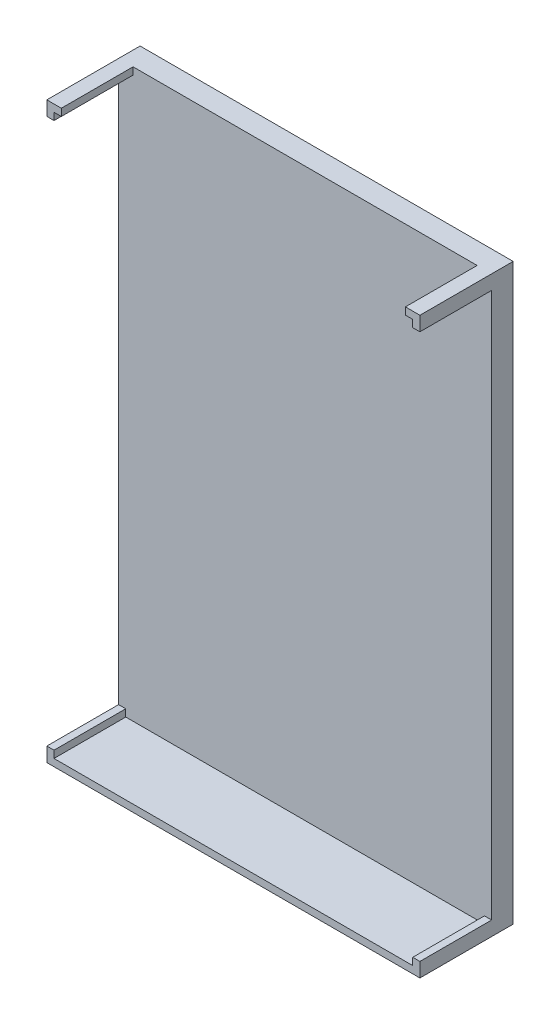
from build123d import *

# Parameters (mm, degrees)
SKETCH_4_W      = 52
SKETCH_4_H      = 80
EXTRUDE_3_DEPTH = 3
EXTRUDE_6_DEPTH = 10
EXTRUDE_7_REACH = 51.979
SKETCH_7_W      = 10
SKETCH_7_H      = 1


with BuildPart() as part:
    # 草图4 → 凸台-拉伸3 (new body)
    with BuildSketch(Plane.XY):
        Rectangle(SKETCH_4_W, SKETCH_4_H)
    extrude(amount=-EXTRUDE_3_DEPTH)

    # 草图6 → 凸台-拉伸6 (add)
    with BuildSketch(Plane.XY):
        Polygon((26, 40), (23.978927851, 40), (23.978927851, 39), (25, 39), (25, 38), (26, 38), align=None)
        Polygon((-25, -38), (-26, -38), (-26, -40), (-23.978927851, -40), (-23.978927851, -39), (-25, -39), align=None)
        Polygon((23.978927851, -39), (23.978927851, -40), (26, -40), (26, -38), (25, -38), (25, -39), align=None)
        Polygon((-26, 40), (-26, 38), (-25, 38), (-25, 39), (-23.978927851, 39), (-23.978927851, 40), align=None)
    extrude(amount=EXTRUDE_6_DEPTH)

    # 草图7 → 凸台-拉伸7 (add, up to next)
    with BuildSketch(Plane(origin=(-23.978927851, 0, 0), x_dir=(0, 0, -1), z_dir=(1, 0, 0)), mode=Mode.PRIVATE) as extrude_7_sk1:
        with Locations((-5, -39.5)):
            Rectangle(SKETCH_7_W, SKETCH_7_H)
    extrude_7_tool1 = extrude(extrude_7_sk1.sketch, amount=EXTRUDE_7_REACH, mode=Mode.PRIVATE) - part.part
    add(extrude_7_tool1.solids().sort_by_distance((-23.978928, -39.5, 5))[0])


solid = part.part
